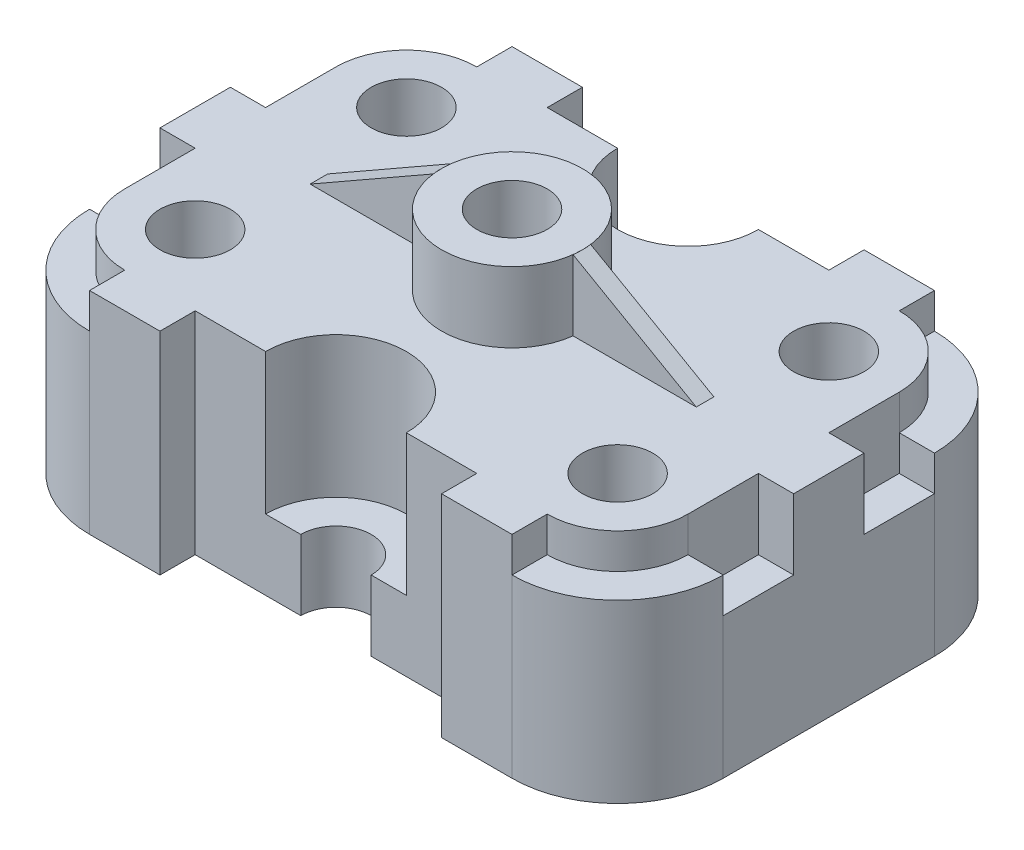
from build123d import *

# Parameters (mm, degrees)
SKETCH1_W           = 180
SKETCH1_H           = 120
BOSS_EXTRUDE2_DEPTH = 80
CUT_EXTRUDE1_DEPTH  = 150
CUT_EXTRUDE2_DEPTH  = 150
SKETCH4_R           = 10
CUT_EXTRUDE3_DEPTH  = 150
CUT_EXTRUDE4_DEPTH  = 60
CUT_EXTRUDE5_DEPTH  = 60
SKETCH7_R           = 10
CUT_EXTRUDE7_DEPTH  = 139
SKETCH8_W           = 80
SKETCH8_H           = 10
CUT_EXTRUDE8_DEPTH  = 139
BOSS_EXTRUDE3_DEPTH = 60
CUT_EXTRUDE9_DEPTH  = 256
CUT_EXTRUDE10_DEPTH = 60
CUT_EXTRUDE11_DEPTH = 60
SKETCH13_W          = 40
SKETCH13_H          = 20
SKETCH13_W_2        = 20
SKETCH13_H_2        = 10
CUT_EXTRUDE12_DEPTH = 209
CUT_EXTRUDE13_DEPTH = 20
CUT_EXTRUDE14_DEPTH = 10
CUT_EXTRUDE15_DEPTH = 10
CUT_EXTRUDE16_DEPTH = 10
CUT_EXTRUDE17_DEPTH = 10
BOSS_EXTRUDE4_DEPTH = 10
BOSS_EXTRUDE5_DEPTH = 10
SKETCH21_W          = 10
SKETCH21_H          = 20
CUT_EXTRUDE20_DEPTH = 20
SKETCH22_W          = 35
SKETCH22_H          = 5
BOSS_EXTRUDE9_DEPTH = 19.999
CUT_EXTRUDE21_DEPTH = 10


with BuildPart() as part:
    # Sketch1 → Boss-Extrude2 (new body)
    with BuildSketch(Plane(origin=(0, 0, 0), x_dir=(1, 0, 0), z_dir=(0, 1, 0))):
        with Locations((90, 60)):
            Rectangle(SKETCH1_W, SKETCH1_H)
    extrude(amount=BOSS_EXTRUDE2_DEPTH)

    # Sketch2 → Cut-Extrude1 (cut)
    with BuildSketch(Plane(origin=(0, 0, 0), x_dir=(1, 0, 0), z_dir=(0, 1, 0))):
        with BuildLine():
            ThreePointArc((30, 0), (8.786796564, 8.786796564), (0, 30))
            Line((0, 30), (0, 0))
            Line((0, 0), (30, 0))
        make_face()
        with BuildLine():
            Line((180, 0), (180, 30))
            ThreePointArc((180, 30), (171.213203436, 8.786796564), (150, 0))
            Line((150, 0), (180, 0))
        make_face()
        with BuildLine():
            Line((180, 120), (150, 120))
            ThreePointArc((150, 120), (171.213203436, 111.213203436), (180, 90))
            Line((180, 90), (180, 120))
        make_face()
        with BuildLine():
            Line((0, 120), (30, 120))
            ThreePointArc((30, 120), (8.786796564, 111.213203436), (0, 90))
            Line((0, 90), (0, 120))
        make_face()
    extrude(amount=CUT_EXTRUDE1_DEPTH, mode=Mode.SUBTRACT)

    # Sketch3 → Cut-Extrude2 (cut)
    with BuildSketch(Plane(origin=(0, 0, 0), x_dir=(1, 0, 0), z_dir=(0, 1, 0))):
        with BuildLine():
            Line((80, 120), (100, 120))
            ThreePointArc((100, 120), (90, 110), (80, 120))
        make_face()
        with BuildLine():
            Line((80, 0), (100, 0))
            ThreePointArc((100, 0), (90, 10), (80, 0))
        make_face()
    extrude(amount=CUT_EXTRUDE2_DEPTH, mode=Mode.SUBTRACT)

    # Sketch4 → Cut-Extrude3 (cut)
    with BuildSketch(Plane(origin=(0, 80, 0), x_dir=(1, 0, 0), z_dir=(0, 1, 0))):
        with Locations(Location((30, 90, 0), (0, 0, 270))):
            Circle(SKETCH4_R)
        with Locations(Location((150, 90, 0), (0, 0, 270))):
            Circle(SKETCH4_R)
        with Locations(Location((150, 30, 0), (0, 0, 270))):
            Circle(SKETCH4_R)
        with Locations(Location((30, 30, 0), (0, 0, 270))):
            Circle(SKETCH4_R)
    extrude(amount=-CUT_EXTRUDE3_DEPTH, mode=Mode.SUBTRACT)

    # Sketch5 → Cut-Extrude4 (cut)
    with BuildSketch(Plane(origin=(0, 80, 0), x_dir=(1, 0, 0), z_dir=(0, 1, 0))):
        with BuildLine():
            Line((70, 120), (80, 120))
            ThreePointArc((80, 120), (90, 110), (100, 120))
            Line((100, 120), (110, 120))
            ThreePointArc((110, 120), (90, 100), (70, 120))
        make_face()
    extrude(amount=-CUT_EXTRUDE4_DEPTH, mode=Mode.SUBTRACT)

    # Sketch6 → Cut-Extrude5 (cut)
    with BuildSketch(Plane(origin=(0, 80, 0), x_dir=(1, 0, 0), z_dir=(0, 1, 0))):
        with BuildLine():
            ThreePointArc((110, 0), (90, 20), (70, 0))
            Line((70, 0), (80, 0))
            ThreePointArc((80, 0), (90, 10), (100, 0))
            Line((100, 0), (110, 0))
        make_face()
    extrude(amount=-CUT_EXTRUDE5_DEPTH, mode=Mode.SUBTRACT)

    # Sketch7 → Cut-Extrude7 (cut)
    with BuildSketch(Plane(origin=(0, 80, 0), x_dir=(1, 0, 0), z_dir=(0, 1, 0))):
        with Locations(Location((90, 60, 0), (0, 0, 270))):
            Circle(SKETCH7_R)
    extrude(amount=-CUT_EXTRUDE7_DEPTH, mode=Mode.SUBTRACT)

    # Sketch8 → Cut-Extrude8 (cut)
    with BuildSketch(Plane(origin=(0, 80, 0), x_dir=(1, 0, 0), z_dir=(0, 1, 0))):
        with Locations((90, 115)):
            Rectangle(SKETCH8_W, SKETCH8_H)
        with Locations((90, 5)):
            Rectangle(SKETCH8_W, SKETCH8_H)
    extrude(amount=-CUT_EXTRUDE8_DEPTH, mode=Mode.SUBTRACT)

    # Sketch9 → Boss-Extrude3 (add)
    with BuildSketch(Plane(origin=(0, 20, 0), x_dir=(1, 0, 0), z_dir=(0, 1, 0))):
        with BuildLine():
            Line((72.679491924, 110), (107.320508076, 110))
            ThreePointArc((107.320508076, 110), (90, 100), (72.679491924, 110))
        make_face()
        with BuildLine():
            Line((72.679491924, 10), (107.320508076, 10))
            ThreePointArc((107.320508076, 10), (90, 20), (72.679491924, 10))
        make_face()
    extrude(amount=BOSS_EXTRUDE3_DEPTH)

    # Sketch10 → Cut-Extrude9 (cut)
    with BuildSketch(Plane(origin=(0, 80, 0), x_dir=(1, 0, 0), z_dir=(0, 1, 0))):
        with BuildLine():
            Line((80, 110), (100, 110))
            ThreePointArc((100, 110), (90, 100), (80, 110))
        make_face()
        with BuildLine():
            Line((80, 10), (100, 10))
            ThreePointArc((100, 10), (90, 20), (80, 10))
        make_face()
    extrude(amount=-CUT_EXTRUDE9_DEPTH, mode=Mode.SUBTRACT)

    # Sketch11 → Cut-Extrude10 (cut)
    with BuildSketch(Plane(origin=(0, 80, 0), x_dir=(1, 0, 0), z_dir=(0, 1, 0))):
        with BuildLine():
            Line((80, 110), (70, 110))
            ThreePointArc((70, 110), (90, 90), (110, 110))
            Line((110, 110), (100, 110))
            ThreePointArc((100, 110), (90, 100), (80, 110))
        make_face()
    extrude(amount=-CUT_EXTRUDE10_DEPTH, mode=Mode.SUBTRACT)

    # Sketch12 → Cut-Extrude11 (cut)
    with BuildSketch(Plane(origin=(0, 80, 0), x_dir=(1, 0, 0), z_dir=(0, 1, 0))):
        with BuildLine():
            ThreePointArc((110, 10), (90, 30), (70, 10))
            Line((70, 10), (80, 10))
            ThreePointArc((80, 10), (90, 20), (100, 10))
            Line((100, 10), (110, 10))
        make_face()
    extrude(amount=-CUT_EXTRUDE11_DEPTH, mode=Mode.SUBTRACT)

    # Sketch13 → Cut-Extrude12 (cut)
    with BuildSketch(Plane(origin=(0, 0, 0), x_dir=(0, 0, -1), z_dir=(1, 0, 0))):
        with Locations((100, 70)):
            Rectangle(SKETCH13_W, SKETCH13_H)
        with Locations((100, 55)):
            Rectangle(SKETCH13_W_2, SKETCH13_H_2)
        with Locations((20, 70)):
            Rectangle(SKETCH13_W, SKETCH13_H)
        with Locations((20, 55)):
            Rectangle(SKETCH13_W_2, SKETCH13_H_2)
    extrude(amount=CUT_EXTRUDE12_DEPTH, mode=Mode.SUBTRACT)

    # Sketch14 → Cut-Extrude13 (cut)
    with BuildSketch(Plane(origin=(0, 80, 0), x_dir=(1, 0, 0), z_dir=(0, 1, 0))):
        with BuildLine():
            Line((90, 80), (0, 80))
            Line((0, 80), (0, 40))
            Line((0, 40), (90, 40))
            ThreePointArc((90, 40), (70, 60), (90, 80))
        make_face()
        with BuildLine():
            Line((180, 80), (90, 80))
            ThreePointArc((90, 80), (104.142135624, 74.142135624), (110, 60))
            ThreePointArc((110, 60), (104.142135624, 45.857864376), (90, 40))
            Line((90, 40), (180, 40))
            Line((180, 40), (180, 80))
        make_face()
    extrude(amount=-CUT_EXTRUDE13_DEPTH, mode=Mode.SUBTRACT)

    # Sketch15 → Cut-Extrude14 (cut)
    with BuildSketch(Plane(origin=(0, 60, 0), x_dir=(1, 0, 0), z_dir=(0, 1, 0))):
        with BuildLine():
            Line((7.639320225, 110), (30, 110))
            Line((30, 110), (30, 120))
            ThreePointArc((30, 120), (17.752551286, 117.386127875), (7.639320225, 110))
        make_face()
    extrude(amount=-CUT_EXTRUDE14_DEPTH, mode=Mode.SUBTRACT)

    # Sketch16 → Cut-Extrude15 (cut)
    with BuildSketch(Plane(origin=(0, 60, 0), x_dir=(1, 0, 0), z_dir=(0, 1, 0))):
        with BuildLine():
            ThreePointArc((7.639320225, 10), (17.752551286, 2.613872125), (30, 0))
            Line((30, 0), (30, 10))
            Line((30, 10), (7.639320225, 10))
        make_face()
    extrude(amount=-CUT_EXTRUDE15_DEPTH, mode=Mode.SUBTRACT)

    # Sketch17 → Cut-Extrude16 (cut)
    with BuildSketch(Plane(origin=(0, 60, 0), x_dir=(1, 0, 0), z_dir=(0, 1, 0))):
        with BuildLine():
            Line((150, 10), (150, 0))
            ThreePointArc((150, 0), (162.247448714, 2.613872125), (172.360679775, 10))
            Line((172.360679775, 10), (150, 10))
        make_face()
    extrude(amount=-CUT_EXTRUDE16_DEPTH, mode=Mode.SUBTRACT)

    # Sketch18 → Cut-Extrude17 (cut)
    with BuildSketch(Plane(origin=(0, 60, 0), x_dir=(1, 0, 0), z_dir=(0, 1, 0))):
        with BuildLine():
            ThreePointArc((172.360679775, 110), (162.247448714, 117.386127875), (150, 120))
            Line((150, 120), (150, 110))
            Line((150, 110), (172.360679775, 110))
        make_face()
    extrude(amount=-CUT_EXTRUDE17_DEPTH, mode=Mode.SUBTRACT)

    # Sketch19 → Boss-Extrude4 (add)
    with BuildSketch(Plane(origin=(0, 50, 0), x_dir=(1, 0, 0), z_dir=(0, 1, 0))):
        with BuildLine():
            Line((40, 90), (90, 90))
            ThreePointArc((90, 90), (75.857864376, 95.857864376), (70, 110))
            Line((70, 110), (30, 110))
            ThreePointArc((30, 110), (15.857864376, 104.142135624), (10, 90))
            Line((10, 90), (20, 90))
            ThreePointArc((20, 90), (30, 100), (40, 90))
        make_face()
        with BuildLine():
            ThreePointArc((170, 90), (164.142135624, 104.142135624), (150, 110))
            Line((150, 110), (130, 110))
            Line((130, 110), (110, 110))
            ThreePointArc((110, 110), (104.142135624, 95.857864376), (90, 90))
            Line((90, 90), (140, 90))
            ThreePointArc((140, 90), (150, 100), (160, 90))
            Line((160, 90), (170, 90))
        make_face()
    extrude(amount=BOSS_EXTRUDE4_DEPTH)

    # Sketch20 → Boss-Extrude5 (add)
    with BuildSketch(Plane(origin=(0, 50, 0), x_dir=(1, 0, 0), z_dir=(0, 1, 0))):
        with BuildLine():
            Line((20, 30), (10, 30))
            ThreePointArc((10, 30), (15.857864376, 15.857864376), (30, 10))
            Line((30, 10), (50, 10))
            Line((50, 10), (70, 10))
            ThreePointArc((70, 10), (75.857864376, 24.142135624), (90, 30))
            Line((90, 30), (40, 30))
            ThreePointArc((40, 30), (30, 20), (20, 30))
        make_face()
        with BuildLine():
            Line((140, 30), (90, 30))
            ThreePointArc((90, 30), (104.142135624, 24.142135624), (110, 10))
            Line((110, 10), (130, 10))
            Line((130, 10), (150, 10))
            ThreePointArc((150, 10), (164.142135624, 15.857864376), (170, 30))
            Line((170, 30), (160, 30))
            ThreePointArc((160, 30), (150, 20), (140, 30))
        make_face()
    extrude(amount=BOSS_EXTRUDE5_DEPTH)

    # Sketch21 → Cut-Extrude20 (cut)
    with BuildSketch(Plane(origin=(0, 60, 0), x_dir=(1, 0, 0), z_dir=(0, 1, 0))):
        with Locations((5, 80)):
            Rectangle(SKETCH21_W, SKETCH21_H)
        with Locations((5, 40)):
            Rectangle(SKETCH21_W, SKETCH21_H)
        with Locations((175, 80)):
            Rectangle(SKETCH21_W, SKETCH21_H)
        with Locations((175, 40)):
            Rectangle(SKETCH21_W, SKETCH21_H)
    extrude(amount=-CUT_EXTRUDE20_DEPTH, mode=Mode.SUBTRACT)

    # Sketch22 → Boss-Extrude9 (add)
    with BuildSketch(Plane(origin=(0, 60, 0), x_dir=(1, 0, 0), z_dir=(0, 1, 0))):
        with BuildLine():
            Line((70.156865167, 62.5), (35.156865167, 62.5))
            Line((35.156865167, 62.5), (35.156865167, 57.5))
            Line((35.156865167, 57.5), (70.156865167, 57.5))
            ThreePointArc((70.156865167, 57.5), (70, 60), (70.156865167, 62.5))
        make_face()
        with Locations((127.343134833, 60)):
            Rectangle(SKETCH22_W, SKETCH22_H)
    extrude(amount=BOSS_EXTRUDE9_DEPTH)

    # Sketch23 → Cut-Extrude21 (cut)
    with BuildSketch(Plane.XY.offset(-57.5)):
        Polygon((35.156865167, 60), (70.156865167, 79.999), (35.156865167, 79.999), align=None)
        Polygon((109.843134833, 79.999), (144.843134833, 60), (144.843134833, 79.999), align=None)
    extrude(amount=-CUT_EXTRUDE21_DEPTH, mode=Mode.SUBTRACT)


solid = part.part
